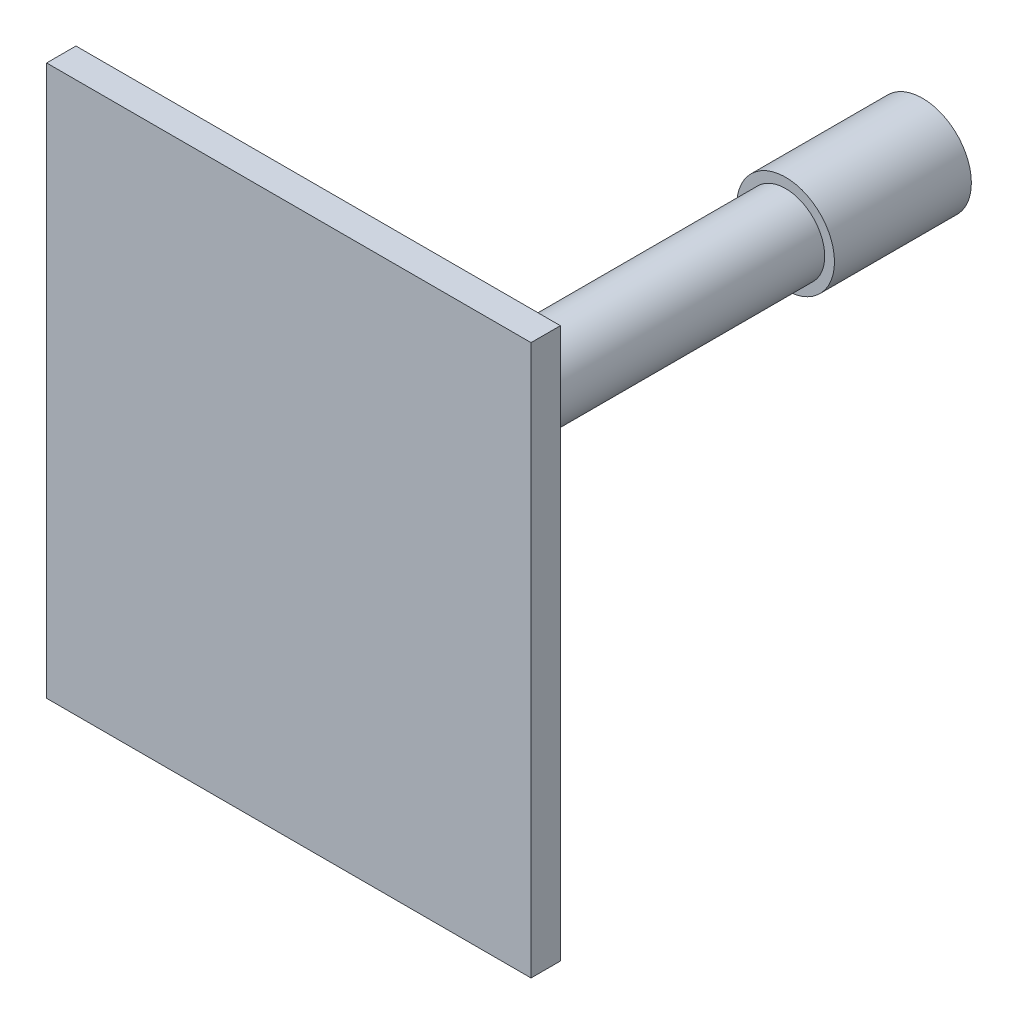
from build123d import *

# Parameters (mm, degrees)
SKETCH2_R           = 15.875
BOSS_EXTRUDE1_DEPTH = 44.45
SKETCH3_R           = 12.7
BOSS_EXTRUDE2_DEPTH = 113.665
SKETCH4_R           = 11.01725
BOSS_EXTRUDE3_DEPTH = 38.1
SKETCH6_R           = 5.55625
CUT_EXTRUDE1_DEPTH  = 215.9
SKETCH8_W           = 157.285598566
SKETCH8_H           = 178.663022366
BOSS_EXTRUDE5_DEPTH = 9.525


with BuildPart() as part:
    # Sketch2 → Boss-Extrude1 (new body)
    with BuildSketch(Plane.XY):
        Circle(SKETCH2_R)
    extrude(amount=BOSS_EXTRUDE1_DEPTH)

    # Sketch3 → Boss-Extrude2 (add)
    with BuildSketch(Plane.XY.offset(44.45)):
        Circle(SKETCH3_R)
    extrude(amount=BOSS_EXTRUDE2_DEPTH)

    # Sketch4 → Boss-Extrude3 (add)
    with BuildSketch(Plane.XY.offset(158.115)):
        Circle(SKETCH4_R)
    extrude(amount=BOSS_EXTRUDE3_DEPTH)

    # Sketch6 → Cut-Extrude1 (cut)
    with BuildSketch(Plane(origin=(0, 0, 0), x_dir=(-1, 0, 0), z_dir=(0, 0, -1))):
        Circle(SKETCH6_R)
    extrude(amount=-CUT_EXTRUDE1_DEPTH, mode=Mode.SUBTRACT)

    # Sketch8 → Boss-Extrude5 (add)
    with BuildSketch(Plane.XY.offset(196.215)):
        Rectangle(SKETCH8_W, SKETCH8_H)
    extrude(amount=BOSS_EXTRUDE5_DEPTH)


solid = part.part
